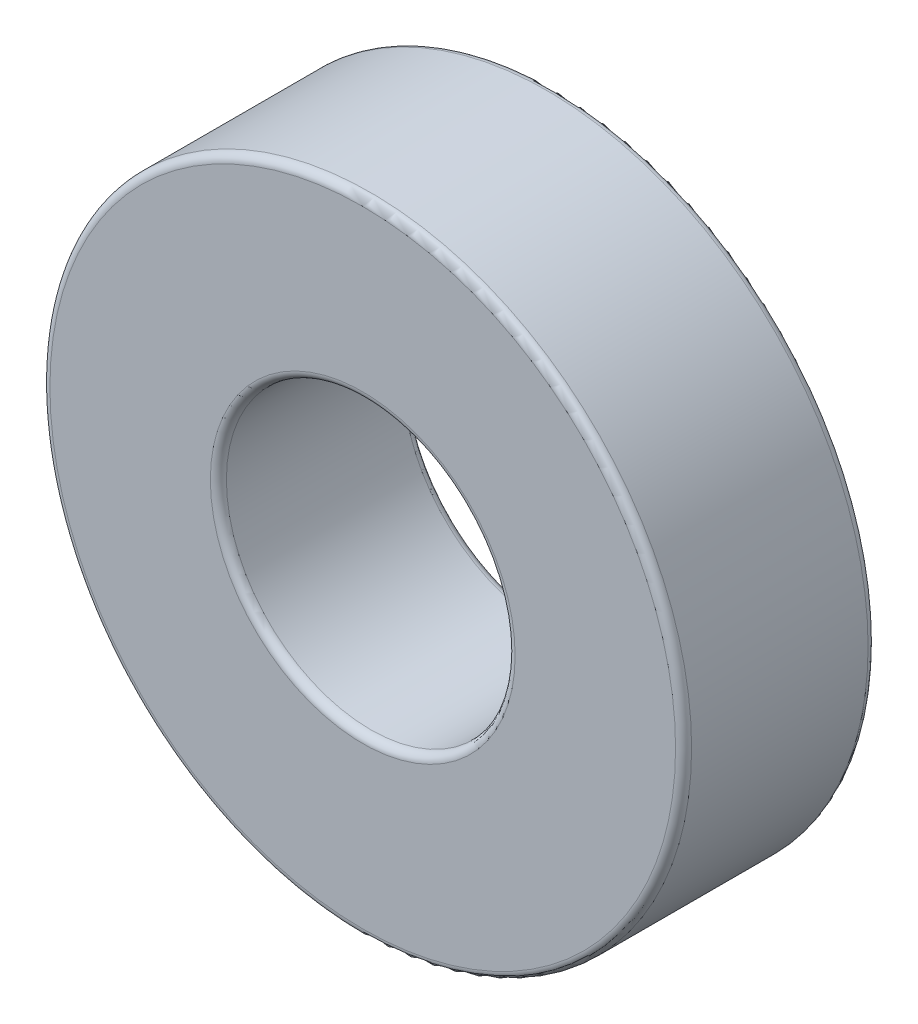
from build123d import *

# Parameters (mm, degrees)
SZKIC1_R                    = 20
DODANIE_WYCI_GNI_CIE1_DEPTH = 12
SZKIC4_R                    = 9
WYTNIJ_WYCI_GNI_CIE1_DEPTH  = 12
ZAOKR_GLENIE1_R             = 0.5


with BuildPart() as part:
    # Szkic1 → Dodanie-wyciągnięcie1 (new body)
    with BuildSketch(Plane.XY):
        Circle(SZKIC1_R)
    extrude(amount=DODANIE_WYCI_GNI_CIE1_DEPTH)

    # Szkic4 → Wytnij-wyciągnięcie1 (cut)
    with BuildSketch(Plane(origin=(0, 0, 0), x_dir=(-1, 0, 0), z_dir=(0, 0, -1))):
        Circle(SZKIC4_R)
    extrude(amount=-WYTNIJ_WYCI_GNI_CIE1_DEPTH, mode=Mode.SUBTRACT)

    # Zaokrąglenie1
    zaokr_glenie1_edges = [part.edges().sort_by_distance(p)[0] for p in [
        (-20, 0, 0),
        (-20, 0, 12),
        (9, 0, 12),
        (9, 0, 0),
    ]]
    fillet(zaokr_glenie1_edges, radius=ZAOKR_GLENIE1_R)


solid = part.part
